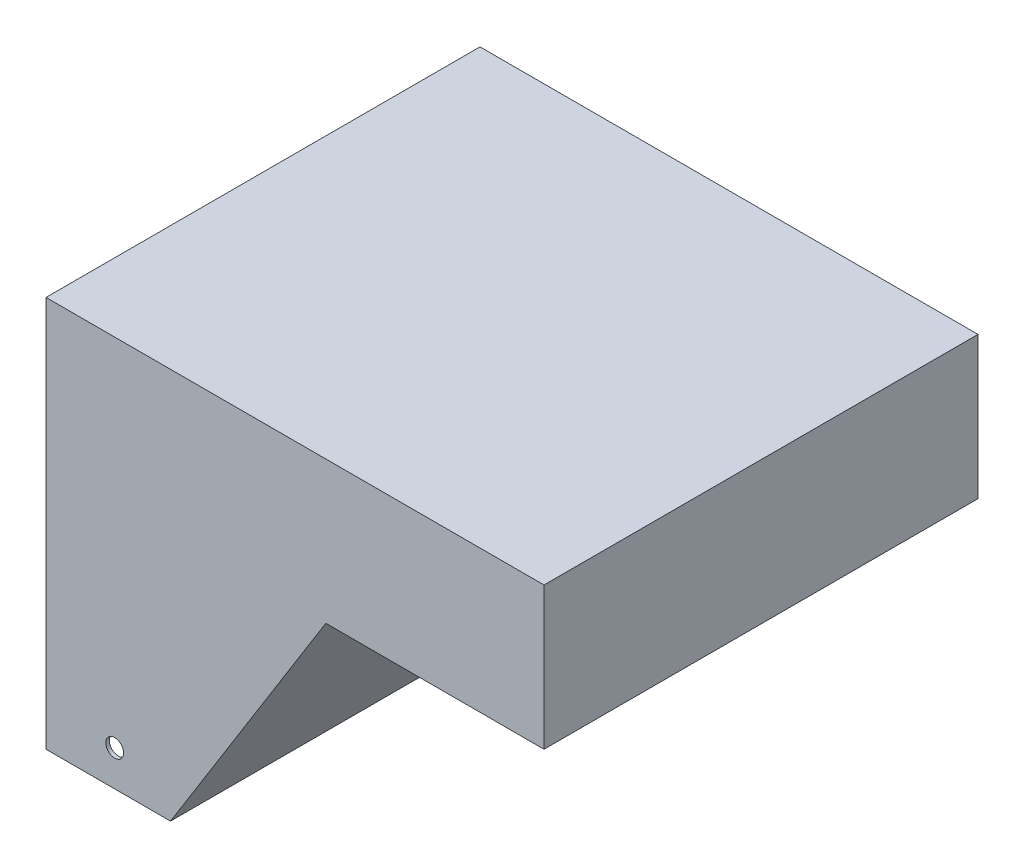
from build123d import *

# Parameters (mm, degrees)
SKETCH2_R           = 6.35
BOSS_EXTRUDE1_DEPTH = 2.54
BOSS_EXTRUDE2_DEPTH = 304.8


with BuildPart() as part:
    # Sketch2 → Boss-Extrude1 (new body)
    with BuildSketch(Plane.XY):
        Polygon((0, 0), (355.6, 0), (355.6, -101.6), (199.80781759, -101.6), (88.9, -279.4), (0, -279.4), align=None)
        with Locations((49.038050814, -254)):
            Circle(SKETCH2_R, mode=Mode.SUBTRACT)
    boss_extrude1 = extrude(amount=BOSS_EXTRUDE1_DEPTH)

    # Sketch3 → Boss-Extrude2 (add)
    with BuildSketch(Plane.XY.offset(2.54)):
        Polygon((2.54, -279.4), (2.54, -276.86), (2.54, -2.54), (353.06, -2.54), (353.06, -99.06), (198.398569196, -99.06), (87.490751606, -276.86), (87.490751606, -279.4), (88.9, -279.4), (199.80781759, -101.6), (355.6, -101.6), (355.6, 0), (0, 0), (0, -279.4), align=None)
    extrude(amount=BOSS_EXTRUDE2_DEPTH)

    # Mirror1: Boss-Extrude1 across plane
    add(boss_extrude1.mirror(Plane.XY.offset(154.94)))


solid = part.part
